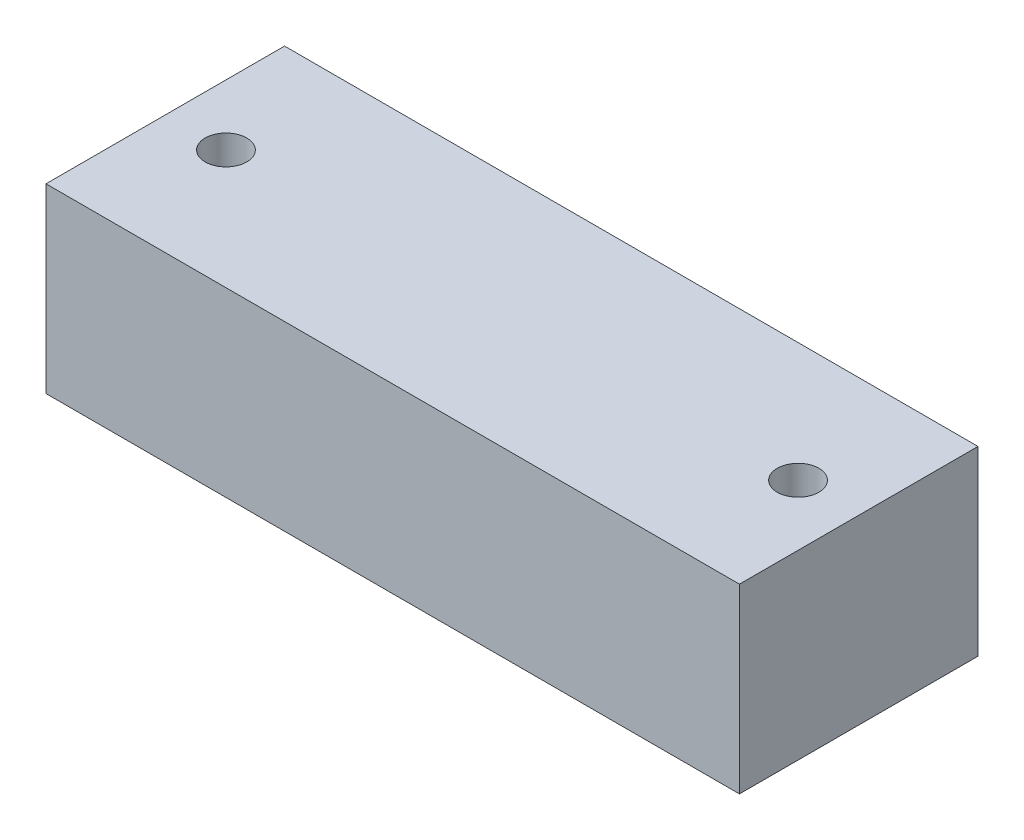
from build123d import *

# Parameters (mm, degrees)
SKETCH1_W           = 63.5
SKETCH1_H           = 21.844
SKETCH1_R           = 1.905
BOSS_EXTRUDE1_DEPTH = 16.637


with BuildPart() as part:
    # Sketch1 → Boss-Extrude1 (new body)
    with BuildSketch(Plane(origin=(0, 0, 0), x_dir=(1, 0, 0), z_dir=(0, 1, 0))):
        with Locations((31.75, 10.922)):
            Rectangle(SKETCH1_W, SKETCH1_H)
        with Locations((5.55625, 10.922)):
            Circle(SKETCH1_R, mode=Mode.SUBTRACT)
        with Locations((57.94375, 10.922)):
            Circle(SKETCH1_R, mode=Mode.SUBTRACT)
    extrude(amount=BOSS_EXTRUDE1_DEPTH)


solid = part.part
